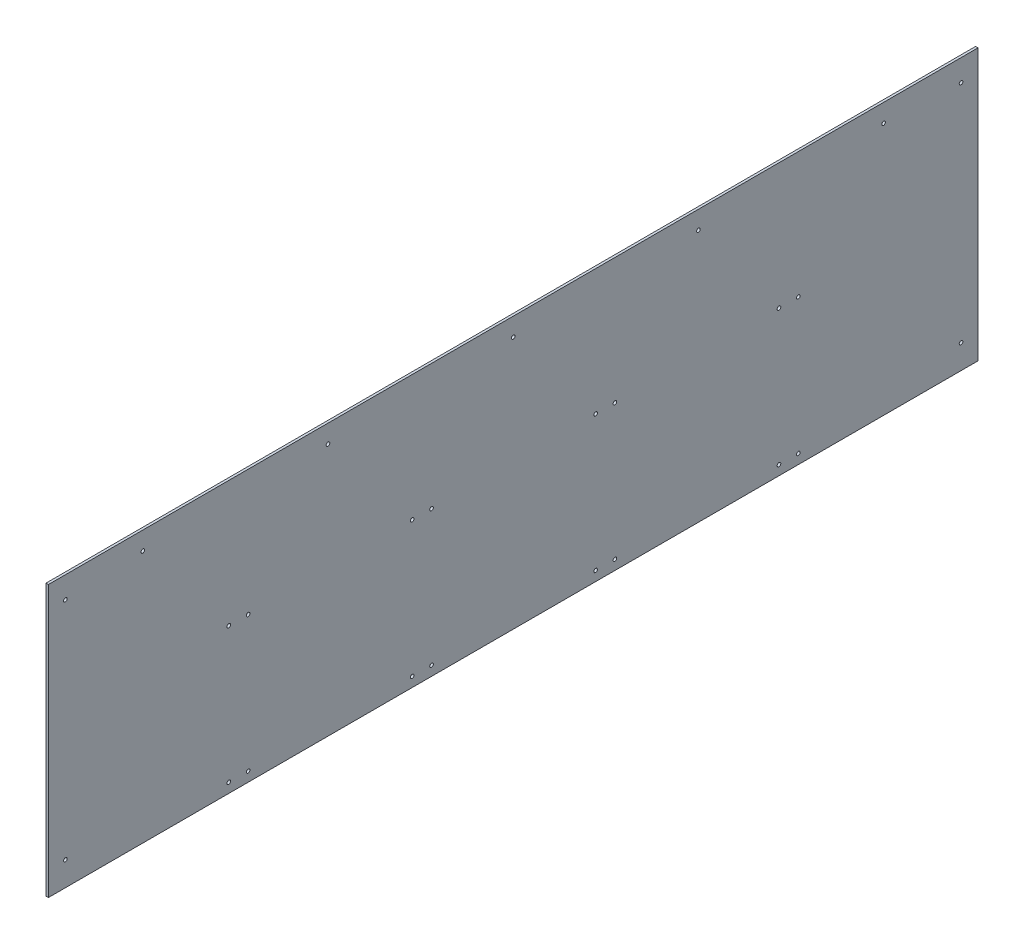
from build123d import *

# Parameters (mm, degrees)
SKETCH1_W                    = 2438.4
SKETCH1_H                    = 711.2
BOSS_EXTRUDE1_DEPTH          = 6.35
F_3_8_0_375_DIAMETER_HOLE3_D = 9.525
LPATTERN1_COUNT              = 4
LPATTERN1_PITCH              = 481.076
F_3_8_0_375_DIAMETER_HOLE2_D = 9.525
LPATTERN2_COUNT              = 5
LPATTERN2_PITCH              = 485.775
F_3_8_0_375_DIAMETER_HOLE1_D = 9.525


with BuildPart() as part:
    # Sketch1 → Boss-Extrude1 (new body)
    with BuildSketch(Plane(origin=(0, 0, 0), x_dir=(0, 0, -1), z_dir=(1, 0, 0))):
        Rectangle(SKETCH1_W, SKETCH1_H)
    extrude(amount=BOSS_EXTRUDE1_DEPTH)

    # 3/8 (0.375) Diameter Hole3 (through all)
    with Locations(Plane(origin=(6.35, 0, 0), x_dir=(0, 0, -1), z_dir=(1, 0, 0))):
        with Locations((-746.125, 25.4), (-695.325, 25.4), (-746.125, -330.2), (-695.325, -330.2)):
            f_3_8_0_375_diameter_hole3 = Hole(F_3_8_0_375_DIAMETER_HOLE3_D / 2)

    # LPattern1: 3/8 (0.375) Diameter Hole3 ×4
    with Locations(*[(0, 0, -i * LPATTERN1_PITCH) for i in range(1, LPATTERN1_COUNT)]):
        add(f_3_8_0_375_diameter_hole3, mode=Mode.SUBTRACT)

    # 3/8 (0.375) Diameter Hole2 (through all)
    with Locations(Plane(origin=(6.35, 0, 0), x_dir=(0, 0, -1), z_dir=(1, 0, 0))):
        with Locations((-971.55, 307.975)):
            f_3_8_0_375_diameter_hole2 = Hole(F_3_8_0_375_DIAMETER_HOLE2_D / 2)

    # LPattern2: 3/8 (0.375) Diameter Hole2 ×5
    with Locations(*[(0, 0, -i * LPATTERN2_PITCH) for i in range(1, LPATTERN2_COUNT)]):
        add(f_3_8_0_375_diameter_hole2, mode=Mode.SUBTRACT)

    # 3/8 (0.375) Diameter Hole1 (through all)
    with Locations(Plane(origin=(6.35, 0, 0), x_dir=(0, 0, -1), z_dir=(1, 0, 0))):
        with Locations((-1174.75, -292.1), (-1174.75, 298.45)):
            f_3_8_0_375_diameter_hole1 = Hole(F_3_8_0_375_DIAMETER_HOLE1_D / 2)

    # Mirror1: 3/8 (0.375) Diameter Hole1 across plane
    add(f_3_8_0_375_diameter_hole1.mirror(Plane.XY), mode=Mode.SUBTRACT)


solid = part.part
